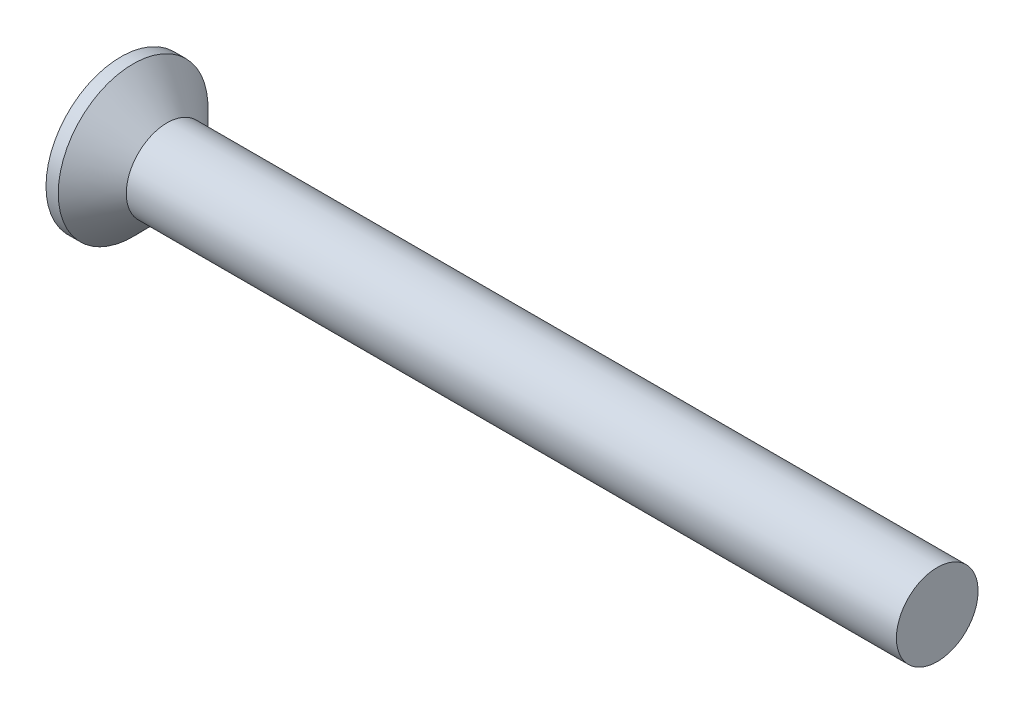
from build123d import *

# Parameters (mm, degrees)
SKETCH3_W         = 0.79
SKETCH3_H         = 3.1
SKETCH4_W         = 0.395
SKETCH4_H         = 0.395
CIRPATTERN1_COUNT = 2
CIRPATTERN1_ANGLE = 90


with BuildPart() as part:
    # BodySke → Base-Revolve (revolve)
    with BuildSketch(Plane.XY):
        Polygon((0, 0), (0, 2.75), (0.45, 2.75), (1.7, 1.5), (30, 1.5), (30, 0), align=None)
    revolve(axis=Axis((-6.35, 0, 0), (1, 0, 0)))

    # Sketch3 → Cross section 0
    with BuildSketch(Plane.ZY):
        Rectangle(SKETCH3_W, SKETCH3_H)
    # Sketch4 → Cross section 1
    with BuildSketch(Plane.ZY.offset(-2.08)):
        Rectangle(SKETCH4_W, SKETCH4_H)
    cross = loft(mode=Mode.SUBTRACT)

    # CirPattern1: Cross ×2 about axis
    cirpattern1_axis = Axis((0, 0, 0), (1, 0, 0))
    for i in range(1, CIRPATTERN1_COUNT):
        add(cross.rotate(cirpattern1_axis, i * CIRPATTERN1_ANGLE / (CIRPATTERN1_COUNT - 1)), mode=Mode.SUBTRACT)


solid = part.part
